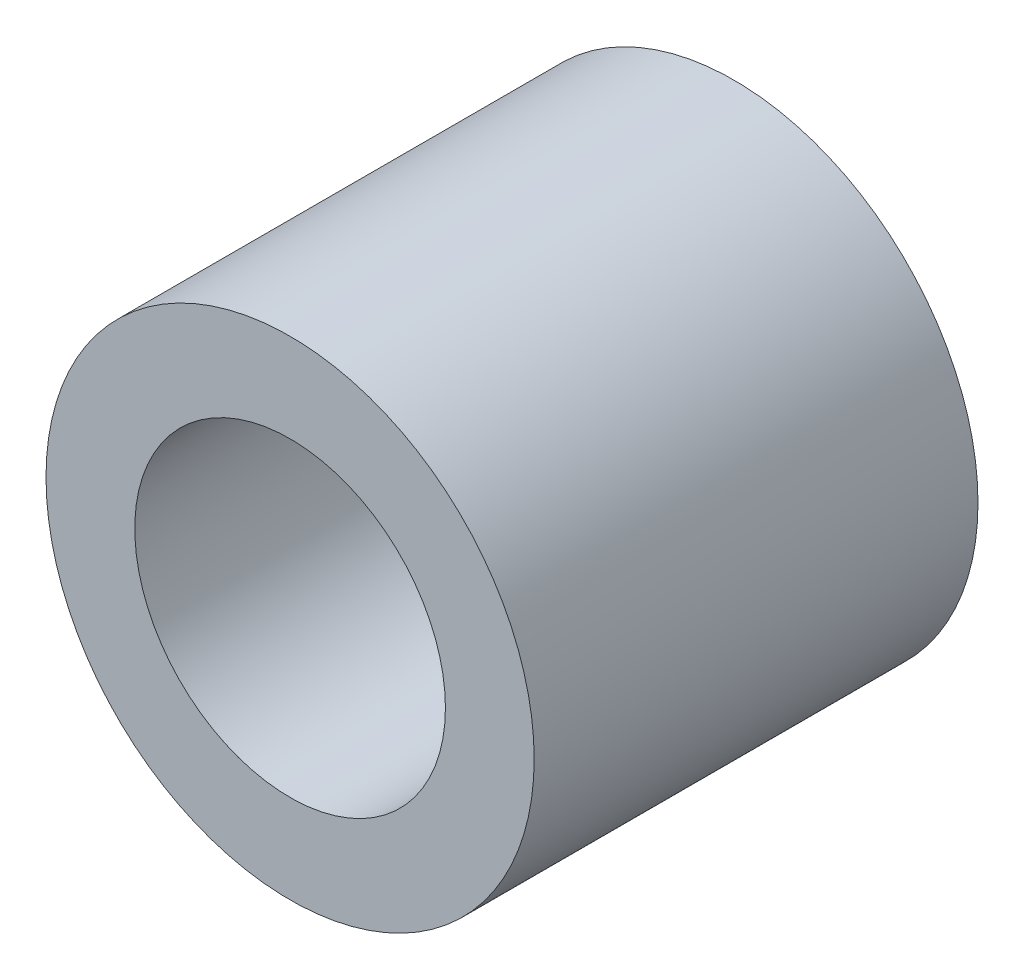
from build123d import *

# Parameters (mm, degrees)
SKETCH1_R           = 2.75
SKETCH1_R_2         = 1.75
BOSS_EXTRUDE1_DEPTH = 5


with BuildPart() as part:
    # Sketch1 → Boss-Extrude1 (new body)
    with BuildSketch(Plane.XY):
        Circle(SKETCH1_R)
        Circle(SKETCH1_R_2, mode=Mode.SUBTRACT)
    extrude(amount=BOSS_EXTRUDE1_DEPTH)


solid = part.part
